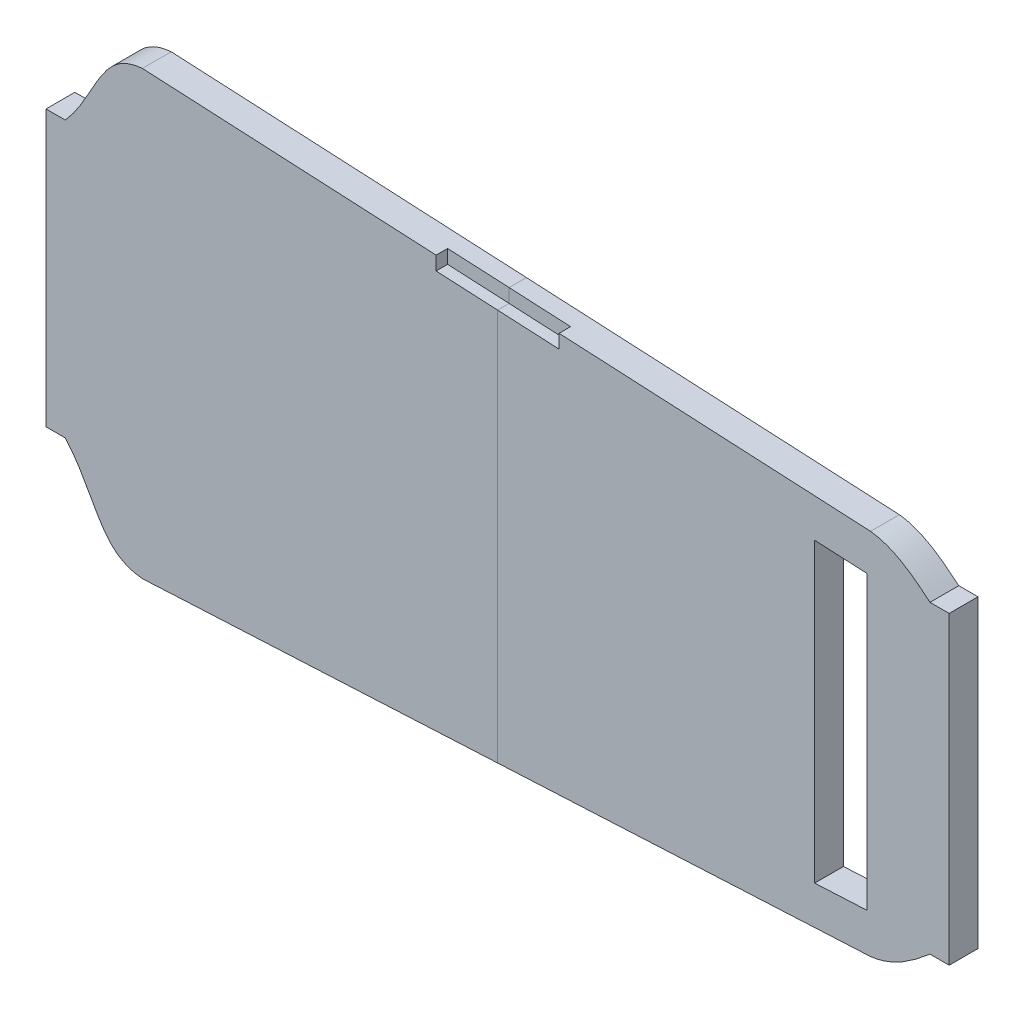
from build123d import *

# Parameters (mm, degrees)
BOSS_EXTRUDE1_DEPTH    = 7.5
CUT_EXTRUDE1_DEPTH     = 149.438464419
CUT_EXTRUDE3_DEPTH     = 3
SPLIT2_SURFACE_1_BACK  = 262.728
SPLIT2_SURFACE_1_DEPTH = 525.456
SPLIT2_SURFACE_2_BACK  = 262.728
SPLIT2_SURFACE_2_DEPTH = 525.456


with BuildPart() as part:
    # Sketch1 → Boss-Extrude1 (new body)
    with BuildSketch(Plane.XY):
        with BuildLine():
            Line((128.959100066, 33.628624999), (133.959100066, 33.628624999))
            Line((133.959100066, 33.628624999), (133.959100066, -45.656116492))
            Line((133.959100066, -45.656116492), (128.959100066, -45.656116492))
            add(Edge.make_bspline(
                [(113.496599029, -53.92747215), (114.973875685, -53.76034768), (116.389465073, -53.408303088), (118.438931288, -52.658652366), (119.109837198, -52.372048444), (120.430638868, -51.735858399), (121.082915856, -51.384782434), (122.988929436, -50.267489711), (124.197203446, -49.437169981), (126.541735842, -47.677906536), (127.677620036, -46.748450374), (128.850515141, -45.74891878), (128.904828159, -45.702543351), (128.959100066, -45.656116492)],
                knots=[0, 0, 0, 0, 0.125, 0.125, 0.1875, 0.1875, 0.25, 0.25, 0.375, 0.375, 0.5, 0.5, 0.506074438, 0.506074438, 0.506074438, 0.506074438], degree=3))
            Line((113.496599029, -53.92747215), (-75.963345356, -63.503442328))
            add(Edge.make_bspline(
                [(-96.040899934, -41.829259963), (-95.798899268, -42.093160096), (-95.56197213, -42.362136183), (-94.03954966, -44.156758027), (-92.923608678, -45.792412437), (-90.858487716, -49.170948695), (-89.911065512, -50.914960796), (-88.457766632, -53.51029646), (-87.967520262, -54.371999904), (-86.940892781, -56.06392928), (-86.404912323, -56.894254814), (-85.530671439, -58.091259413), (-85.227414802, -58.482089731), (-84.588818098, -59.241614046), (-84.254184704, -59.609132259), (-83.204929916, -60.651600397), (-82.440569541, -61.270576891), (-81.160629249, -62.042718444), (-80.719255742, -62.269433113), (-79.817314106, -62.660888928), (-79.3554021, -62.826549047), (-77.940467092, -63.243286827), (-76.954208328, -63.414201398), (-75.963345356, -63.503442328)],
                knots=[0.352672192, 0.352672192, 0.352672192, 0.352672192, 0.375, 0.375, 0.5, 0.5, 0.625, 0.625, 0.6875, 0.6875, 0.75, 0.75, 0.78125, 0.78125, 0.8125, 0.8125, 0.875, 0.875, 0.90625, 0.90625, 0.9375, 0.9375, 1, 1, 1, 1], degree=3))
            Line((-96.040899934, -41.829259963), (-101.040899934, -41.829259963))
            Line((-101.040899934, -41.829259963), (-101.040899934, 29.801740739))
            Line((-101.040899934, 29.801740739), (-96.040899934, 29.801740739))
            add(Edge.make_bspline(
                [(-75.963345356, 51.475952827), (-76.969760945, 51.385311169), (-77.956664013, 51.213742336), (-79.395866789, 50.78571401), (-79.86970863, 50.613871194), (-80.796837185, 50.204577199), (-81.240590365, 49.971323111), (-82.089787414, 49.449496549), (-82.495246976, 49.160946736), (-83.271465049, 48.533739024), (-83.643007435, 48.194375714), (-84.708444042, 47.116795042), (-85.333215001, 46.343374139), (-86.491296884, 44.737676097), (-87.023827607, 43.904896882), (-88.044872363, 42.211012893), (-88.533034054, 41.34968138), (-89.982900727, 38.756279626), (-90.93240726, 37.013628654), (-92.999467157, 33.650383947), (-94.114586107, 32.031232641), (-95.60337212, 30.287705281), (-95.819744565, 30.042891916), (-96.040899934, 29.801740739)],
                knots=[0, 0, 0, 0, 0.0625, 0.0625, 0.09375, 0.09375, 0.125, 0.125, 0.15625, 0.15625, 0.1875, 0.1875, 0.25, 0.25, 0.3125, 0.3125, 0.375, 0.375, 0.5, 0.5, 0.625, 0.625, 0.645748558, 0.645748558, 0.645748558, 0.645748558], degree=3))
            Line((-75.963345356, 51.475952827), (113.496599029, 41.899982649))
            add(Edge.make_bspline(
                [(128.959100066, 33.628624999), (128.913387154, 33.667730585), (127.751192536, 34.660386778), (126.568806099, 35.629041088), (124.805320754, 36.953884089), (124.207009004, 37.38378621), (122.992052543, 38.206145046), (122.374602128, 38.599251589), (120.484333172, 39.709851881), (119.174169326, 40.359663675), (117.093195419, 41.124643977), (116.387101294, 41.341482025), (114.957490187, 41.687263925), (114.232477088, 41.816732683), (113.496599029, 41.899982649)],
                knots=[0.494878569, 0.494878569, 0.494878569, 0.494878569, 0.5, 0.625, 0.625, 0.6875, 0.6875, 0.75, 0.75, 0.875, 0.875, 0.9375, 0.9375, 1, 1, 1, 1], degree=3))
        make_face()
    extrude(amount=BOSS_EXTRUDE1_DEPTH)

    # Sketch3 → Cut-Extrude1 (cut, through all)
    with BuildSketch(Plane.XY.offset(7.5)):
        Polygon((98.959100066, 32.621993758), (98.959100066, -44.649483258), (112.616012614, -43.959214992), (112.616329261, 31.931709487), align=None)
    extrude(amount=-CUT_EXTRUDE1_DEPTH, mode=Mode.SUBTRACT)

    # Sketch5 → Cut-Extrude3 (cut)
    with BuildSketch(Plane.XY.offset(7.5)):
        Polygon((0.459100066, 47.61329436), (0.459100066, 44.038083245), (32.459100066, 42.420690995), (32.459100066, 45.99590211), align=None)
    extrude(amount=-CUT_EXTRUDE3_DEPTH, mode=Mode.SUBTRACT)


with BuildPart() as body_2:
    # Split2: the piece behind the surface
    add(part.part)
    # Split2 surface: a surface, the sketch's curves swept straight by 525.456 mm
    with BuildLine(Plane.XY.offset(7.5).offset(-SPLIT2_SURFACE_1_BACK), mode=Mode.PRIVATE) as split2_surface_1_path:
        Line((16.459100066, 62.942434119), (16.459100066, -80.716271859))
    split2_surface_1 = Shell.extrude(split2_surface_1_path.wire(), (0 * SPLIT2_SURFACE_1_DEPTH, 0 * SPLIT2_SURFACE_1_DEPTH, 1 * SPLIT2_SURFACE_1_DEPTH))
    split(bisect_by=split2_surface_1, keep=Keep.BOTTOM)


with BuildPart() as part_1:
    add(part.part)

    # Split2: split by a surface, the side it looks to stays
    # Split2 surface: a surface, the sketch's curves swept straight by 525.456 mm
    with BuildLine(Plane.XY.offset(7.5).offset(-SPLIT2_SURFACE_2_BACK), mode=Mode.PRIVATE) as split2_surface_2_path:
        Line((16.459100066, 62.942434119), (16.459100066, -80.716271859))
    split2_surface_2 = Shell.extrude(split2_surface_2_path.wire(), (0 * SPLIT2_SURFACE_2_DEPTH, 0 * SPLIT2_SURFACE_2_DEPTH, 1 * SPLIT2_SURFACE_2_DEPTH))
    split(bisect_by=split2_surface_2, keep=Keep.TOP)


solid = Compound([body_2.part, part_1.part])
